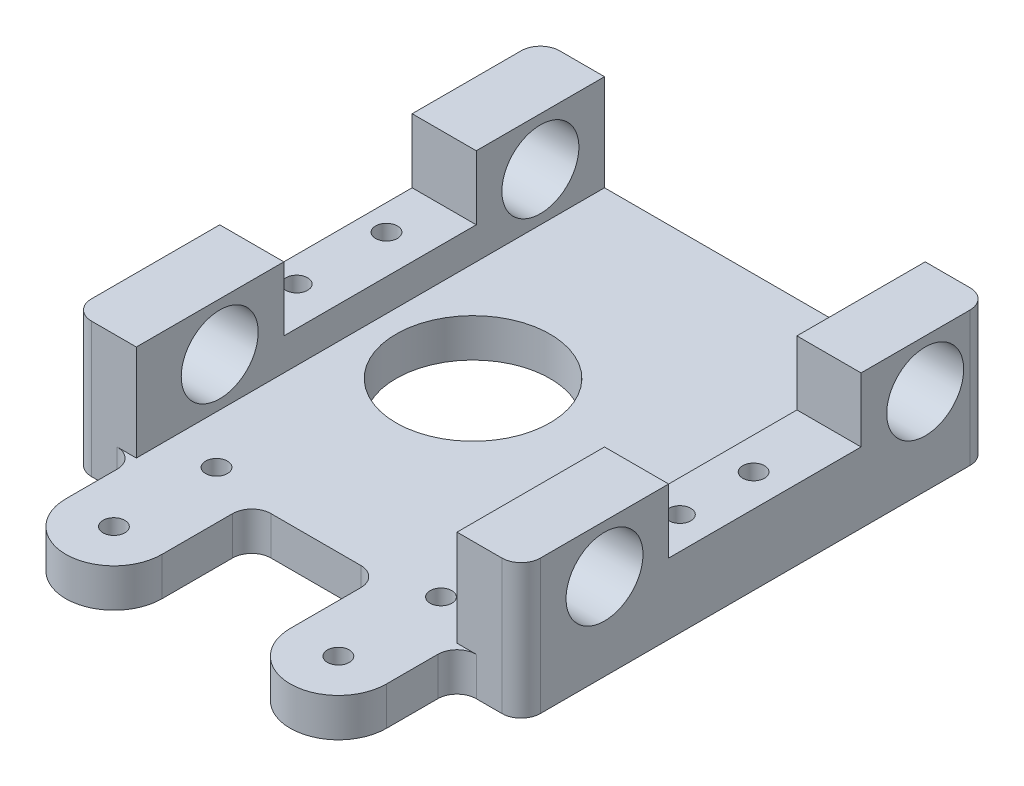
from build123d import *

# Parameters (mm, degrees)
ESQUISSE1_R             = 12
BOSS_EXTRU_1_DEPTH      = 6
ESQUISSE3_W             = 10
ESQUISSE3_H             = 73
BOSS_EXTRU_2_DEPTH      = 15
ESQUISSE4_R             = 6
ESQUISSE4_W             = 30
ESQUISSE4_H             = 10
ENL_V_MAT_EXTRU_1_DEPTH = 71
D_GAGEMENT_M32_D        = 3.4
D_GAGEMENT_M32_DEPTH    = 11
CONG_2_R                = 3


with BuildPart() as part:
    # Esquisse1 → Boss.-Extru.1 (new body)
    with BuildSketch(Plane(origin=(0, 0, 0), x_dir=(1, 0, 0), z_dir=(0, 1, 0))):
        with BuildLine():
            Line((0, 0), (70, 0))
            Line((70, 0), (70, -73))
            Line((70, -73), (60, -73))
            Line((60, -73), (60, -84))
            ThreePointArc((60, -84), (52.5, -91.5), (45, -84))
            Line((45, -84), (45, -70))
            Line((45, -70), (25, -70))
            Line((25, -70), (25, -84))
            ThreePointArc((25, -84), (17.5, -91.5), (10, -84))
            Line((10, -84), (10, -73))
            Line((10, -73), (0, -73))
            Line((0, -73), (0, 0))
        make_face()
        with Locations((25.5, -36)):
            Circle(ESQUISSE1_R, mode=Mode.SUBTRACT)
    extrude(amount=BOSS_EXTRU_1_DEPTH)

    # Esquisse3 → Boss.-Extru.2 (add)
    with BuildSketch(Plane(origin=(0, 6, 0), x_dir=(1, 0, 0), z_dir=(0, 1, 0))):
        with Locations((5, -36.5)):
            Rectangle(ESQUISSE3_W, ESQUISSE3_H)
        with Locations((65, -36.5)):
            Rectangle(ESQUISSE3_W, ESQUISSE3_H)
    extrude(amount=BOSS_EXTRU_2_DEPTH)

    # Esquisse4 → Enlèv. mat.-Extru.1 (cut, through all)
    with BuildSketch(Plane(origin=(0, 0, 0), x_dir=(0, 0, -1), z_dir=(1, 0, 0))):
        with Locations((-60, 13.5)):
            Circle(ESQUISSE4_R)
        with Locations((-10, 13.5)):
            Circle(ESQUISSE4_R)
        with Locations((-35, 16)):
            Rectangle(ESQUISSE4_W, ESQUISSE4_H)
    extrude(amount=ENL_V_MAT_EXTRU_1_DEPTH, mode=Mode.SUBTRACT)

    # Dégagement M32
    with Locations(Plane(origin=(0, 11, 0), x_dir=(1, 0, 0), z_dir=(0, 1, 0))):
        with Locations((4, -28), (4, -42), (17.5, -84), (52.5, -84), (17.5, -68), (52.5, -68), (65, -31.75), (65, -43.25)):
            Hole(D_GAGEMENT_M32_D / 2, depth=D_GAGEMENT_M32_DEPTH)

    # Congé2
    cong_2_edges = [part.edges().sort_by_distance(p)[0] for p in [
        (0, 10.5, 0),
        (70, 10.5, 0),
        (70, 10.5, 73),
        (60, 3, 73),
        (45, 3, 70),
        (25, 3, 70),
        (10, 3, 73),
        (0, 10.5, 73),
    ]]
    fillet(cong_2_edges, radius=CONG_2_R)


solid = part.part
